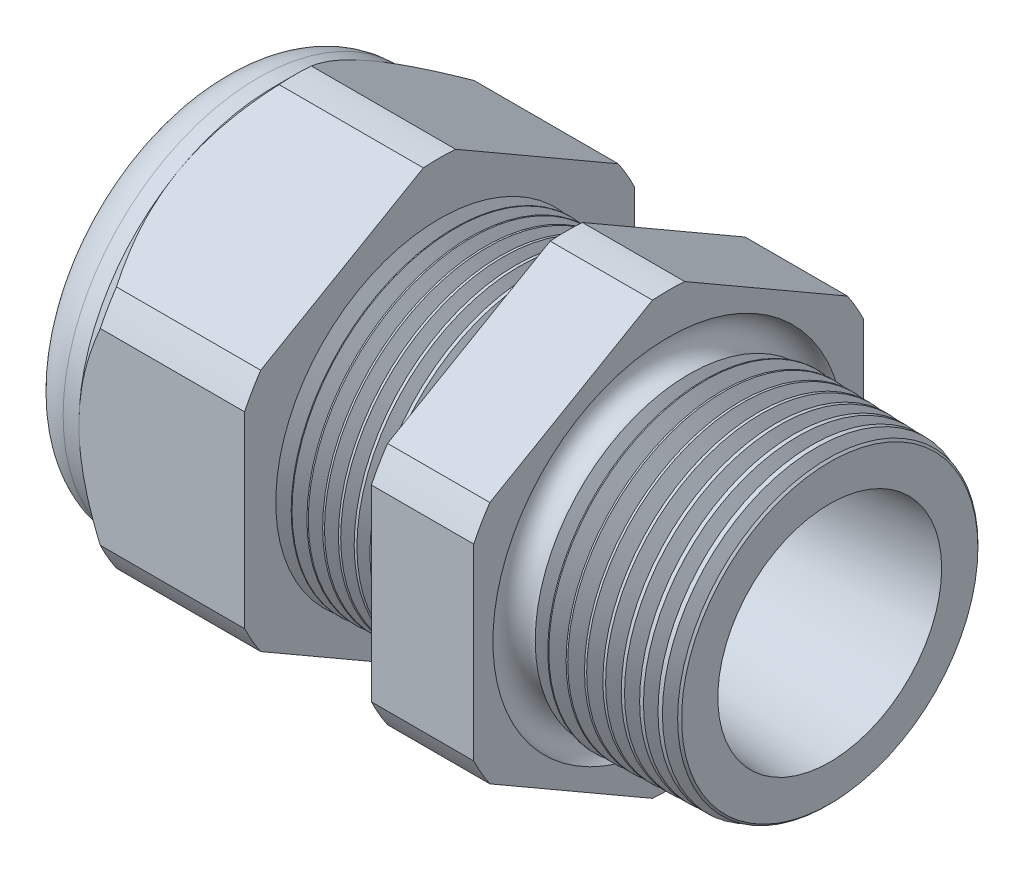
from build123d import *

# Parameters (mm, degrees)
SKETCH12_OUTSIDE_W = 52.432
SKETCH12_OUTSIDE_H = 52.432
CUT_EXTRUDE2_DEPTH = 28.172
FILLET4_R          = 2.032
SKETCH19_OUTSIDE_W = 33.316
SKETCH19_OUTSIDE_H = 35.412
SKETCH19_OUTSIDE_R = 9.525
CUT_EXTRUDE3_DEPTH = 1.999996
CUT_EXTRUDE3_DRAFT = -45
CHAMFER1_SIZE      = 0.260919487
CHAMFER1_SIZE2     = 0.254
SKETCH21_R         = 3.937
PLUG_DEPTH         = 3.81
SKETCH22_R         = 3.683
CUT_EXTRUDE4_DEPTH = 0.508
SKETCH27_R         = 0.762
PLUGHOLES_DEPTH    = 30.464
CIRPATTERN1_COUNT  = 4
SKETCH28_R         = 0.762
MIDHOLE_DEPTH      = 30.464
LPATTERN1_COUNT    = 8
LPATTERN1_PITCH    = 0.762
LPATTERN2_COUNT    = 9
LPATTERN2_PITCH    = 0.889
SKETCH32_R         = 0.889


with BuildPart() as part:
    # Sketch10 → Revolve2 (revolve)
    with BuildSketch(Plane.XY, mode=Mode.PRIVATE) as revolve2_sk:
        Polygon((-29.972, 3.937), (-19.072, 3.937), (0, 5.469582104), (0, 7.501582104), (-7.874, 7.70777005), (-7.874, 19.05), (-12.874, 19.05), (-12.874, 7.838699658), (-19.072, 8.001), (-19.072, 19.05), (-27.172, 19.05), (-27.172, 9.525), (-29.972, 9.525), align=None)
    revolve(revolve2_sk.sketch.rotate(Axis((0, 0, 0), (-1, 0, 0)), 90), axis=Axis((0, 0, 0), (-1, 0, 0)))  # turned: the seam where the file's is

    # Sketch12 outside → Cut-Extrude2 (cut, through all)
    with BuildSketch(Plane.ZY.offset(27.172)):
        Rectangle(SKETCH12_OUTSIDE_W, SKETCH12_OUTSIDE_H)
        with BuildLine():
            Line((-0.788451287, 10.543310065), (-8.736548713, 5.954473877))
            ThreePointArc((-8.736548713, 5.954473877), (-9.156270088, 5.286375), (-9.525, 4.588836188))
            Line((-9.525, 4.588836188), (-9.525, -4.588836188))
            ThreePointArc((-9.525, -4.588836188), (-9.156270088, -5.286375), (-8.736548713, -5.954473877))
            Line((-8.736548713, -5.954473877), (-0.788451287, -10.543310065))
            ThreePointArc((-0.788451287, -10.543310065), (0, -10.57275), (0.788451287, -10.543310065))
            Line((0.788451287, -10.543310065), (8.736548713, -5.954473877))
            ThreePointArc((8.736548713, -5.954473877), (9.156270088, -5.286375), (9.525, -4.588836188))
            Line((9.525, -4.588836188), (9.525, 4.588836188))
            ThreePointArc((9.525, 4.588836188), (9.156270088, 5.286375), (8.736548713, 5.954473877))
            Line((8.736548713, 5.954473877), (0.788451287, 10.543310065))
            ThreePointArc((0.788451287, 10.543310065), (0, 10.57275), (-0.788451287, 10.543310065))
        make_face(mode=Mode.SUBTRACT)
    extrude(amount=-CUT_EXTRUDE2_DEPTH, mode=Mode.SUBTRACT)

    # Fillet4
    fillet4_edges = [part.edges().sort_by_distance(p)[0] for p in [
        (-29.972, 0, 9.525),
    ]]
    fillet(fillet4_edges, radius=FILLET4_R)


with BuildPart() as cut_extrude3_tool:
    # Sketch19 outside → Cut-Extrude3 (with draft: the straight prism first)
    with BuildSketch(Plane.ZY.offset(27.172)):
        Rectangle(SKETCH19_OUTSIDE_W, SKETCH19_OUTSIDE_H)
        Circle(SKETCH19_OUTSIDE_R, mode=Mode.SUBTRACT)
    extrude(amount=-CUT_EXTRUDE3_DEPTH)
    # Cut-Extrude3: the draft: its side faces are tilted about the plane it starts from
    cut_extrude3_sides = [cut_extrude3_tool.faces().sort_by_distance(p)[0] for p in [
        (-26.172002, -17.706, 0),
        (-26.172002, 0, 16.658),
        (-26.172002, 17.706, 0),
        (-26.172002, 0, -16.658),
        (-26.172002, 0, -9.525),
    ]]
    draft(cut_extrude3_sides, Plane.ZY.offset(27.172), CUT_EXTRUDE3_DRAFT)


with BuildPart() as part_1:
    add(part.part)

    # Cut-Extrude3: cut by cut_extrude3_tool
    add(cut_extrude3_tool.part, mode=Mode.SUBTRACT)

    # Chamfer1
    chamfer1_edges = [part_1.edges().sort_by_distance(p)[0] for p in [
        (0, 0, 7.501582104),
    ]]
    chamfer1_side = [part_1.faces().sort_by_distance(p)[0] for p in [
        (0, 0, 5.681758887),
    ]]
    chamfer(chamfer1_edges, length=CHAMFER1_SIZE, length2=CHAMFER1_SIZE2, reference=chamfer1_side[0])

    # Sketch29 → Cut-Revolve1 (revolve, cut)
    with BuildSketch(Plane.XY, mode=Mode.PRIVATE) as cut_revolve1_sk:
        Polygon((-19.072, 8.001), (-18.339016419, 7.981806149), (-18.722130572, 7.356620673), align=None)
    cut_revolve1 = revolve(cut_revolve1_sk.sketch.rotate(Axis((0, 0, 0), (-1, 0, 0)), 90), axis=Axis((0, 0, 0), (-1, 0, 0)), mode=Mode.SUBTRACT)  # turned: the seam where the file's is

    # LPattern1: Cut-Revolve1 ×8
    with Locations(*[(i * LPATTERN1_PITCH, 0, 0) for i in range(1, LPATTERN1_COUNT)]):
        add(cut_revolve1, mode=Mode.SUBTRACT)

    # Sketch30 → Cut-Revolve2 (revolve, cut)
    with BuildSketch(Plane.XY, mode=Mode.PRIVATE) as cut_revolve2_sk:
        Polygon((-7.874, 7.70777005), (-6.994419703, 7.68473743), (-7.454156686, 6.934514858), align=None)
    cut_revolve2 = revolve(cut_revolve2_sk.sketch.rotate(Axis((0, 0, 0), (-1, 0, 0)), 270), axis=Axis((0, 0, 0), (-1, 0, 0)), mode=Mode.SUBTRACT)  # turned: the seam where the file's is

    # LPattern2: Cut-Revolve2 ×9
    with Locations(*[(i * LPATTERN2_PITCH, 0, 0) for i in range(1, LPATTERN2_COUNT)]):
        add(cut_revolve2, mode=Mode.SUBTRACT)

    # Sketch32 → Cut-Revolve3 (revolve, cut)
    with BuildSketch(Plane.XY, mode=Mode.PRIVATE) as cut_revolve3_sk:
        with Locations((-7.747, 7.70777005)):
            Circle(SKETCH32_R)
    revolve(cut_revolve3_sk.sketch.rotate(Axis((0, 0, 0), (-1, 0, 0)), 270), axis=Axis((0, 0, 0), (-1, 0, 0)), mode=Mode.SUBTRACT)  # turned: the seam where the file's is


with BuildPart() as body_2:
    # Sketch21 → plug (new body)
    with BuildSketch(Plane.ZY.offset(29.972)):
        Circle(SKETCH21_R)
    extrude(amount=-PLUG_DEPTH)

    # Sketch22 → Cut-Extrude4 (cut)
    with BuildSketch(Plane.ZY.offset(29.972)):
        Circle(SKETCH22_R)
    extrude(amount=-CUT_EXTRUDE4_DEPTH, mode=Mode.SUBTRACT)

    # Sketch27 → plugholes (cut, through all)
    with BuildSketch(Plane.ZY.offset(29.464)):
        with Locations((-2.917952, 0)):
            Circle(SKETCH27_R)
    plugholes = extrude(amount=-PLUGHOLES_DEPTH, mode=Mode.SUBTRACT)

    # CirPattern1: plugholes ×4 about axis
    cirpattern1_axis = Axis((0, 0, 0), (1, 0, 0))
    for i in range(1, CIRPATTERN1_COUNT):
        add(plugholes.rotate(cirpattern1_axis, i * 360 / CIRPATTERN1_COUNT), mode=Mode.SUBTRACT)

    # Sketch28 → midhole (cut, through all)
    with BuildSketch(Plane.ZY.offset(29.464)):
        Circle(SKETCH28_R)
    extrude(amount=-MIDHOLE_DEPTH, mode=Mode.SUBTRACT)


solid = Compound([part_1.part, body_2.part])
